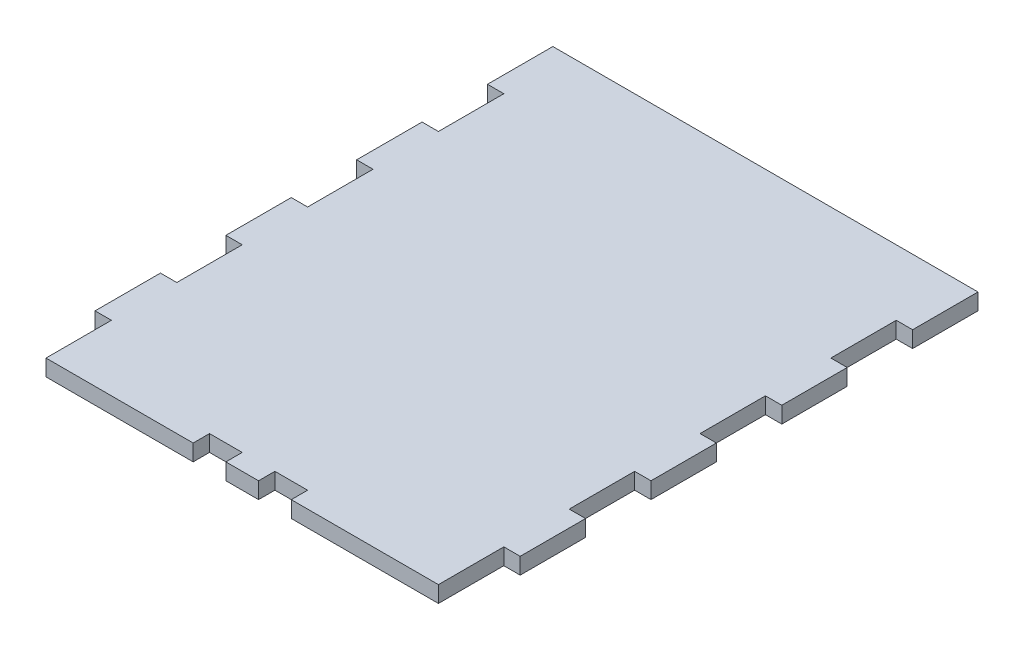
from build123d import *

# Parameters (mm, degrees)
BOSS_EXTRUDE1_DEPTH = 3.175
SKETCH2_W           = 6.35
SKETCH2_H           = 3.175
CUT_EXTRUDE1_DEPTH  = 4.175


with BuildPart() as part:
    # Sketch1 → Boss-Extrude1 (new body)
    with BuildSketch(Plane(origin=(0, 0, 0), x_dir=(1, 0, 0), z_dir=(0, 1, 0))):
        Polygon((0, 0), (76.2, 0), (76.2, 12.7), (79.375, 12.7), (79.375, 25.4), (76.2, 25.4), (76.2, 38.1), (79.375, 38.1), (79.375, 50.8), (76.2, 50.8), (76.2, 63.5), (79.375, 63.5), (79.375, 76.2), (76.2, 76.2), (76.2, 88.9), (79.375, 88.9), (79.375, 101.6), (-3.175, 101.6), (-3.175, 88.9), (0, 88.9), (0, 76.2), (-3.175, 76.2), (-3.175, 63.5), (0, 63.5), (0, 50.8), (-3.175, 50.8), (-3.175, 38.1), (0, 38.1), (0, 25.4), (-3.175, 25.4), (-3.175, 12.7), (0, 12.7), align=None)
    extrude(amount=BOSS_EXTRUDE1_DEPTH)

    # Sketch2 → Cut-Extrude1 (cut, through all)
    with BuildSketch(Plane(origin=(0, 3.175, 0), x_dir=(1, 0, 0), z_dir=(0, 1, 0))):
        with Locations((44.45, 1.5875)):
            Rectangle(SKETCH2_W, SKETCH2_H)
        with Locations((31.75, 1.5875)):
            Rectangle(SKETCH2_W, SKETCH2_H)
    extrude(amount=-CUT_EXTRUDE1_DEPTH, mode=Mode.SUBTRACT)


solid = part.part
